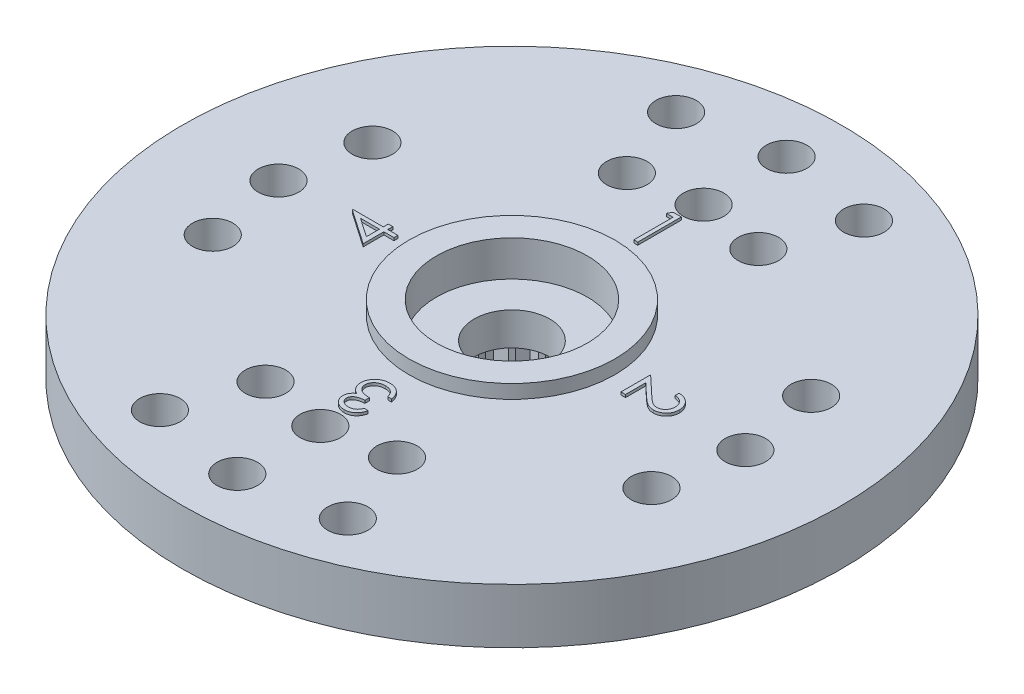
from build123d import *

# Parameters (mm, degrees)
SKETCH1_R           = 12
SKETCH1_R_2         = 1.375
SKETCH1_R_3         = 0.7366
BOSS_EXTRUDE1_DEPTH = 2
SKETCH2_R           = 3.75
SKETCH2_R_2         = 2.75
BOSS_EXTRUDE2_DEPTH = 0.5
SKETCH3_R           = 2.75
SKETCH3_R_2         = 1.375
CUT_EXTRUDE1_DEPTH  = 0.8
SKETCH4_R           = 4.5
SKETCH4_R_2         = 2.5
BOSS_EXTRUDE3_DEPTH = 2.5
CUT_EXTRUDE3_DEPTH  = 2.5
BOSS_EXTRUDE4_DEPTH = 0.1


with BuildPart() as part:
    # Sketch1 → Boss-Extrude1 (new body)
    with BuildSketch(Plane(origin=(0, 0, 0), x_dir=(1, 0, 0), z_dir=(0, 1, 0))):
        with Locations(Location((0, 0, 0), (0, 0, 270))):
            Circle(SKETCH1_R)
        with Locations(Location((0, 0, 0), (0, 0, 270))):
            Circle(SKETCH1_R_2, mode=Mode.SUBTRACT)
        with Locations(Location((0, 10, 0), (0, 0, 270))):
            Circle(SKETCH1_R_3, mode=Mode.SUBTRACT)
        with Locations(Location((-3.420201433, 9.396926208, 0), (0, 0, 270))):
            Circle(SKETCH1_R_3, mode=Mode.SUBTRACT)
        with Locations(Location((3.420201433, 9.396926208, 0), (0, 0, 270))):
            Circle(SKETCH1_R_3, mode=Mode.SUBTRACT)
        with Locations(Location((0, 6.977694875, 0), (0, 0, 270))):
            Circle(SKETCH1_R_3, mode=Mode.SUBTRACT)
        with Locations(Location((-2.394141003, 6.577848346, 0), (0, 0, 270))):
            Circle(SKETCH1_R_3, mode=Mode.SUBTRACT)
        with Locations(Location((2.394141003, 6.577848346, 0), (0, 0, 270))):
            Circle(SKETCH1_R_3, mode=Mode.SUBTRACT)
        with Locations(Location((8.5, 0, 0), (0, 0, 270))):
            Circle(SKETCH1_R_3, mode=Mode.SUBTRACT)
        with Locations(Location((7.987387277, 2.907171218, 0), (0, 0, 270))):
            Circle(SKETCH1_R_3, mode=Mode.SUBTRACT)
        with Locations(Location((7.987387277, -2.907171218, 0), (0, 0, 270))):
            Circle(SKETCH1_R_3, mode=Mode.SUBTRACT)
        with Locations(Location((-2.394141003, -6.577848346, 0), (0, 0, 90))):
            Circle(SKETCH1_R_3, mode=Mode.SUBTRACT)
        with Locations(Location((0, -6.977694875, 0), (0, 0, 90))):
            Circle(SKETCH1_R_3, mode=Mode.SUBTRACT)
        with Locations(Location((2.394141003, -6.577848346, 0), (0, 0, 90))):
            Circle(SKETCH1_R_3, mode=Mode.SUBTRACT)
        with Locations(Location((3.420201433, -9.396926208, 0), (0, 0, 90))):
            Circle(SKETCH1_R_3, mode=Mode.SUBTRACT)
        with Locations(Location((0, -10, 0), (0, 0, 90))):
            Circle(SKETCH1_R_3, mode=Mode.SUBTRACT)
        with Locations(Location((-3.420201433, -9.396926208, 0), (0, 0, 90))):
            Circle(SKETCH1_R_3, mode=Mode.SUBTRACT)
        with Locations(Location((-7.987387277, -2.907171218, 0), (0, 0, 90))):
            Circle(SKETCH1_R_3, mode=Mode.SUBTRACT)
        with Locations(Location((-8.5, 0, 0), (0, 0, 90))):
            Circle(SKETCH1_R_3, mode=Mode.SUBTRACT)
        with Locations(Location((-7.987387277, 2.907171218, 0), (0, 0, 90))):
            Circle(SKETCH1_R_3, mode=Mode.SUBTRACT)
    extrude(amount=BOSS_EXTRUDE1_DEPTH)

    # Sketch2 → Boss-Extrude2 (add)
    with BuildSketch(Plane(origin=(0, 2, 0), x_dir=(1, 0, 0), z_dir=(0, 1, 0))):
        with Locations(Location((0, 0, 0), (0, 0, 270))):
            Circle(SKETCH2_R)
        with Locations(Location((0, 0, 0), (0, 0, 270))):
            Circle(SKETCH2_R_2, mode=Mode.SUBTRACT)
    extrude(amount=BOSS_EXTRUDE2_DEPTH)

    # Sketch3 → Cut-Extrude1 (cut)
    with BuildSketch(Plane(origin=(0, 2, 0), x_dir=(1, 0, 0), z_dir=(0, 1, 0))):
        with Locations(Location((0, 0, 0), (0, 0, 270))):
            Circle(SKETCH3_R)
        with Locations(Location((0, 0, 0), (0, 0, 270))):
            Circle(SKETCH3_R_2, mode=Mode.SUBTRACT)
    extrude(amount=-CUT_EXTRUDE1_DEPTH, mode=Mode.SUBTRACT)

    # Sketch4 → Boss-Extrude3 (add)
    with BuildSketch(Plane.XZ):
        with Locations(Location((0, 0, 0), (0, 0, 90))):
            Circle(SKETCH4_R)
        with Locations(Location((0, 0, 0), (0, 0, 270))):
            Circle(SKETCH4_R_2, mode=Mode.SUBTRACT)
    extrude(amount=BOSS_EXTRUDE3_DEPTH)

    # Sketch5 → Cut-Extrude3 (cut)
    with BuildSketch(Plane.XZ.offset(2.5)):
        with BuildLine():
            Line((0.299038106, 2.482050808), (0, 3))
            Line((0, 3), (-0.299038106, 2.482050808))
            ThreePointArc((-0.299038106, 2.482050808), (-0.391086163, 2.469220851), (-0.482593741, 2.452978451))
            Line((-0.482593741, 2.452978451), (-0.927050983, 2.853169549))
            Line((-0.927050983, 2.853169549), (-1.051398019, 2.268162738))
            ThreePointArc((-1.051398019, 2.268162738), (-1.134976249, 2.22751631), (-1.216985951, 2.183791473))
            Line((-1.216985951, 2.183791473), (-1.763355757, 2.427050983))
            Line((-1.763355757, 2.427050983), (-1.70083977, 1.832251096))
            ThreePointArc((-1.70083977, 1.832251096), (-1.767766953, 1.767766953), (-1.832251096, 1.70083977))
            Line((-1.832251096, 1.70083977), (-2.427050983, 1.763355757))
            Line((-2.427050983, 1.763355757), (-2.183791473, 1.216985951))
            ThreePointArc((-2.183791473, 1.216985951), (-2.22751631, 1.134976249), (-2.268162738, 1.051398019))
            Line((-2.268162738, 1.051398019), (-2.853169549, 0.927050983))
            Line((-2.853169549, 0.927050983), (-2.452978451, 0.482593741))
            ThreePointArc((-2.452978451, 0.482593741), (-2.469220851, 0.391086163), (-2.482050808, 0.299038106))
            Line((-2.482050808, 0.299038106), (-3, 0))
            Line((-3, 0), (-2.482050808, -0.299038106))
            ThreePointArc((-2.482050808, -0.299038106), (-2.469220851, -0.391086163), (-2.452978451, -0.482593741))
            Line((-2.452978451, -0.482593741), (-2.853169549, -0.927050983))
            Line((-2.853169549, -0.927050983), (-2.268162738, -1.051398019))
            ThreePointArc((-2.268162738, -1.051398019), (-2.22751631, -1.134976249), (-2.183791473, -1.216985951))
            Line((-2.183791473, -1.216985951), (-2.427050983, -1.763355757))
            Line((-2.427050983, -1.763355757), (-1.832251096, -1.70083977))
            ThreePointArc((-1.832251096, -1.70083977), (-1.767766953, -1.767766953), (-1.70083977, -1.832251096))
            Line((-1.70083977, -1.832251096), (-1.763355757, -2.427050983))
            Line((-1.763355757, -2.427050983), (-1.216985951, -2.183791473))
            ThreePointArc((-1.216985951, -2.183791473), (-1.134976249, -2.22751631), (-1.051398019, -2.268162738))
            Line((-1.051398019, -2.268162738), (-0.927050983, -2.853169549))
            Line((-0.927050983, -2.853169549), (-0.482593741, -2.452978451))
            ThreePointArc((-0.482593741, -2.452978451), (-0.391086163, -2.469220851), (-0.299038106, -2.482050808))
            Line((-0.299038106, -2.482050808), (0, -3))
            Line((0, -3), (0.299038106, -2.482050808))
            ThreePointArc((0.299038106, -2.482050808), (0.391086163, -2.469220851), (0.482593741, -2.452978451))
            Line((0.482593741, -2.452978451), (0.927050983, -2.853169549))
            Line((0.927050983, -2.853169549), (1.051398019, -2.268162738))
            ThreePointArc((1.051398019, -2.268162738), (1.134976249, -2.22751631), (1.216985951, -2.183791473))
            Line((1.216985951, -2.183791473), (1.763355757, -2.427050983))
            Line((1.763355757, -2.427050983), (1.70083977, -1.832251096))
            ThreePointArc((1.70083977, -1.832251096), (1.767766953, -1.767766953), (1.832251096, -1.70083977))
            Line((1.832251096, -1.70083977), (2.427050983, -1.763355757))
            Line((2.427050983, -1.763355757), (2.183791473, -1.216985951))
            ThreePointArc((2.183791473, -1.216985951), (2.22751631, -1.134976249), (2.268162738, -1.051398019))
            Line((2.268162738, -1.051398019), (2.853169549, -0.927050983))
            Line((2.853169549, -0.927050983), (2.452978451, -0.482593741))
            ThreePointArc((2.452978451, -0.482593741), (2.469220851, -0.391086163), (2.482050808, -0.299038106))
            Line((2.482050808, -0.299038106), (3, 0))
            Line((3, 0), (2.482050808, 0.299038106))
            ThreePointArc((2.482050808, 0.299038106), (2.469220851, 0.391086163), (2.452978451, 0.482593741))
            Line((2.452978451, 0.482593741), (2.853169549, 0.927050983))
            Line((2.853169549, 0.927050983), (2.268162738, 1.051398019))
            ThreePointArc((2.268162738, 1.051398019), (2.22751631, 1.134976249), (2.183791473, 1.216985951))
            Line((2.183791473, 1.216985951), (2.427050983, 1.763355757))
            Line((2.427050983, 1.763355757), (1.832251096, 1.70083977))
            ThreePointArc((1.832251096, 1.70083977), (1.767766953, 1.767766953), (1.70083977, 1.832251096))
            Line((1.70083977, 1.832251096), (1.763355757, 2.427050983))
            Line((1.763355757, 2.427050983), (1.216985951, 2.183791473))
            ThreePointArc((1.216985951, 2.183791473), (1.134976249, 2.22751631), (1.051398019, 2.268162738))
            Line((1.051398019, 2.268162738), (0.927050983, 2.853169549))
            Line((0.927050983, 2.853169549), (0.482593741, 2.452978451))
            ThreePointArc((0.482593741, 2.452978451), (0.391086163, 2.469220851), (0.299038106, 2.482050808))
        make_face()
    extrude(amount=-CUT_EXTRUDE3_DEPTH, mode=Mode.SUBTRACT)

    # Sketch6 → Boss-Extrude4 (add)
    with BuildSketch(Plane(origin=(0, 2, 0), x_dir=(1, 0, 0), z_dir=(0, 1, 0))):
        Polygon((-0.212111879, 6.0875), (0.081410256, 6.0875), (0.081410256, 4.5), (-0.061057692, 4.5), (-0.061057692, 5.924679487), (-0.305288462, 5.924679487), align=None)
        with BuildLine():
            Line((5.599038462, 0.34599359), (5.599038462, 0.488461538))
            add(Edge.make_bspline(
                [(5.599038462, 0.488461538), (5.617939279, 0.487533166), (5.655059981, 0.485709868), (5.709180577, 0.477167658), (5.760917347, 0.46495614), (5.809826741, 0.447649569), (5.856493025, 0.426277468), (5.900296523, 0.40011183), (5.941671981, 0.369710466), (5.979836023, 0.335129148), (6.014722729, 0.29760523), (6.045167992, 0.25736354), (6.070596953, 0.214817686), (6.091970581, 0.170336692), (6.107994605, 0.123406123), (6.119889389, 0.074474582), (6.127044708, 0.023320904), (6.12781392, -0.011531495), (6.128205128, -0.029256811)],
                knots=[0, 0, 0, 0, 1.100776268, 2.161895295, 3.184016182, 4.190939212, 5.176500551, 6.166955529, 7.155448256, 8.160289653, 9.16017456, 10.133824356, 11.091467644, 12.04088621, 13.000931625, 13.972173743, 14.968683325, 16, 16, 16, 16], degree=3))
            add(Edge.make_bspline(
                [(6.128205128, -0.029256811), (6.127797614, -0.046664009), (6.126996863, -0.080868531), (6.120120254, -0.130789516), (6.109349932, -0.178313503), (6.094239011, -0.223347597), (6.073926074, -0.265532491), (6.049525047, -0.305185086), (6.02130391, -0.342777454), (5.988078073, -0.376616959), (5.952607706, -0.407690267), (5.914739978, -0.434497361), (5.875628838, -0.457454046), (5.834976046, -0.476589172), (5.79239883, -0.490675349), (5.748517063, -0.501369751), (5.702876523, -0.507414685), (5.671985336, -0.50834243), (5.656280048, -0.508814103)],
                knots=[0, 0, 0, 0, 1.111607364, 2.184268762, 3.212621178, 4.221274766, 5.211760367, 6.196651075, 7.1921475, 8.207485113, 9.220403448, 10.201281604, 11.166441695, 12.114753415, 13.065576456, 14.026450734, 14.996634279, 16, 16, 16, 16], degree=3))
            add(Edge.make_bspline(
                [(5.656280048, -0.508814103), (5.634169423, -0.508046087), (5.590336183, -0.506523533), (5.525922299, -0.493499512), (5.463513856, -0.473158416), (5.413286579, -0.448666758), (5.372812816, -0.423959614), (5.339489511, -0.401694923), (5.30360953, -0.375630526), (5.265293024, -0.345387065), (5.224239863, -0.311590155), (5.180474849, -0.273933674), (5.134450153, -0.232149094), (5.103015113, -0.202821846), (5.086726262, -0.1876252)],
                knots=[0, 0, 0, 0, 1.184426356, 2.348067706, 3.509069118, 4.696110526, 5.333549288, 6.050745305, 6.844228056, 7.710549037, 8.667450064, 9.695053472, 10.805634456, 12, 12, 12, 12], degree=3))
            Line((5.086726262, -0.1876252), (4.662820513, 0.209567808))
            Line((4.662820513, 0.209567808), (4.662820513, -0.529166667))
            Line((4.662820513, -0.529166667), (4.5, -0.529166667))
            Line((4.5, -0.529166667), (4.5, 0.549519231))
            Line((4.5, 0.549519231), (5.15700621, -0.066145833))
            add(Edge.make_bspline(
                [(5.15700621, -0.066145833), (5.172652803, -0.081136472), (5.202706705, -0.10993042), (5.246597776, -0.15063927), (5.287268318, -0.187261175), (5.324898551, -0.219820431), (5.359275147, -0.248343825), (5.390667508, -0.272740096), (5.418806234, -0.293117072), (5.451862432, -0.31471242), (5.492269991, -0.335305017), (5.541401752, -0.353403803), (5.592090897, -0.364360562), (5.626334746, -0.36568164), (5.643559696, -0.366346154)],
                knots=[0, 0, 0, 0, 1.329530082, 2.553755191, 3.672934919, 4.687409497, 5.60679272, 6.413407421, 7.126401618, 7.737995624, 8.834647426, 9.90044882, 10.943907757, 12, 12, 12, 12], degree=3))
            add(Edge.make_bspline(
                [(5.643559696, -0.366346154), (5.654392812, -0.366060761), (5.675742806, -0.365498307), (5.707024672, -0.360440353), (5.737316681, -0.353009214), (5.766244292, -0.341555532), (5.794376458, -0.327794356), (5.820857871, -0.310213439), (5.846591221, -0.290123068), (5.87069413, -0.266819222), (5.892776139, -0.241235929), (5.912335573, -0.214204803), (5.928681993, -0.185607306), (5.94208205, -0.155562618), (5.952593749, -0.124154868), (5.959877459, -0.091323211), (5.964450586, -0.057158391), (5.965069336, -0.033829626), (5.965384615, -0.021942608)],
                knots=[0, 0, 0, 0, 0.991504627, 1.954065223, 2.895985987, 3.842598665, 4.797835564, 5.759220273, 6.74786863, 7.784730864, 8.824135544, 9.839918996, 10.835834653, 11.835434876, 12.84861661, 13.863796685, 14.911511676, 16, 16, 16, 16], degree=3))
            add(Edge.make_bspline(
                [(5.965384615, -0.021942608), (5.965060395, -0.009527925), (5.964423681, 0.014852462), (5.959967009, 0.050647099), (5.952285925, 0.084797422), (5.941755322, 0.117372561), (5.928497209, 0.148403903), (5.911665037, 0.177610862), (5.891915995, 0.205260088), (5.869403165, 0.231300798), (5.844219896, 0.255228126), (5.816492727, 0.276692883), (5.786041295, 0.295000051), (5.753553406, 0.311228532), (5.718165248, 0.323645722), (5.680734357, 0.334259816), (5.64072893, 0.341970171), (5.613166096, 0.344630175), (5.599038462, 0.34599359)],
                knots=[0, 0, 0, 0, 1.031212865, 2.025131798, 2.990757446, 3.934781266, 4.865570067, 5.788494791, 6.729227313, 7.684356718, 8.643577152, 9.610526866, 10.590658432, 11.59095419, 12.621640561, 13.700587263, 14.82141059, 16, 16, 16, 16], degree=3))
        make_face()
        with BuildLine():
            Line((0.34599359, -5.721153846), (0.488461538, -5.721153846))
            add(Edge.make_bspline(
                [(0.488461538, -5.721153846), (0.484601849, -5.737134294), (0.477056473, -5.768374763), (0.461318645, -5.813009485), (0.444173983, -5.855247654), (0.423586782, -5.894298373), (0.401131025, -5.930946447), (0.37540322, -5.964360657), (0.347590345, -5.995390823), (0.316826886, -6.022928613), (0.284564958, -6.04786494), (0.250349969, -6.069126127), (0.2148703, -6.08741601), (0.177880129, -6.102483759), (0.139269329, -6.113834621), (0.099386965, -6.122070029), (0.05812852, -6.127418142), (0.030121577, -6.127940095), (0.015900441, -6.128205128)],
                knots=[0, 0, 0, 0, 1.162005537, 2.271625781, 3.343758855, 4.383309926, 5.390229558, 6.379919256, 7.361854164, 8.333198761, 9.295911338, 10.242430842, 11.177959212, 12.116337295, 13.062827104, 14.020064771, 14.994644689, 16, 16, 16, 16], degree=3))
            add(Edge.make_bspline(
                [(0.015900441, -6.128205128), (-0.004819946, -6.127579549), (-0.045808747, -6.126342036), (-0.106026272, -6.115041559), (-0.164095579, -6.097159445), (-0.21938106, -6.072451719), (-0.270733706, -6.041977474), (-0.316424762, -6.005707754), (-0.355834908, -5.964342356), (-0.388897715, -5.918652943), (-0.414785304, -5.86982348), (-0.43387448, -5.819567694), (-0.445495743, -5.7680048), (-0.447001853, -5.733189891), (-0.44775641, -5.715747696)],
                knots=[0, 0, 0, 0, 1.083050992, 2.142477498, 3.193116406, 4.255571735, 5.30263384, 6.308962982, 7.297363603, 8.282367274, 9.249857812, 10.179914175, 11.08814088, 12, 12, 12, 12], degree=3))
            add(Edge.make_bspline(
                [(-0.44775641, -5.715747696), (-0.447228639, -5.698962472), (-0.446195871, -5.666116392), (-0.437426655, -5.618164141), (-0.422669136, -5.572969558), (-0.402226779, -5.530342388), (-0.375764719, -5.490552907), (-0.343709603, -5.453511592), (-0.305835181, -5.419054153), (-0.277133663, -5.399314963), (-0.262357272, -5.389152644)],
                knots=[0, 0, 0, 0, 1.024540389, 2.004866551, 2.965041327, 3.920577974, 4.882998113, 5.874504559, 6.905732034, 8, 8, 8, 8], degree=3))
            add(Edge.make_bspline(
                [(-0.262357272, -5.389152644), (-0.279266057, -5.38102782), (-0.312821544, -5.364904106), (-0.358097689, -5.332780608), (-0.399825574, -5.296601576), (-0.422822908, -5.268052723), (-0.43440004, -5.253680889)],
                knots=[0, 0, 0, 0, 1.015663554, 2.015584519, 3.001021554, 4, 4, 4, 4], degree=3))
            add(Edge.make_bspline(
                [(-0.43440004, -5.253680889), (-0.442041901, -5.243223667), (-0.457200483, -5.222480465), (-0.475858316, -5.189110161), (-0.492978135, -5.155480456), (-0.505577827, -5.120269074), (-0.516450862, -5.084607067), (-0.523604956, -5.047730768), (-0.528197599, -5.009990535), (-0.5288425, -4.984446887), (-0.529166667, -4.971607071)],
                knots=[0, 0, 0, 0, 1.02516404, 2.033540309, 3.025129118, 4.011046665, 4.991655828, 5.976607087, 6.982917762, 8, 8, 8, 8], degree=3))
            add(Edge.make_bspline(
                [(-0.529166667, -4.971607071), (-0.528350817, -4.94937866), (-0.526722958, -4.905026444), (-0.512235463, -4.839481871), (-0.489636803, -4.775530087), (-0.458141824, -4.71407805), (-0.418998333, -4.656756936), (-0.372686258, -4.605322495), (-0.319156288, -4.561514187), (-0.259966982, -4.524586511), (-0.195593193, -4.495321744), (-0.127013944, -4.474234108), (-0.05463527, -4.461584484), (-0.005138768, -4.460066765), (0.020034555, -4.459294872)],
                knots=[0, 0, 0, 0, 0.955619592, 1.906742024, 2.874954321, 3.868585453, 4.869520953, 5.854611167, 6.836527075, 7.836578462, 8.849204403, 9.870874567, 10.917152508, 12, 12, 12, 12], degree=3))
            add(Edge.make_bspline(
                [(0.020034555, -4.459294872), (0.037005812, -4.459692103), (0.070399587, -4.460473722), (0.11951096, -4.465721886), (0.166290723, -4.475567824), (0.211193125, -4.487950453), (0.253540479, -4.505070826), (0.293941914, -4.525481482), (0.332220335, -4.549705826), (0.36814842, -4.577784596), (0.401687783, -4.60921458), (0.431983954, -4.644517919), (0.459372127, -4.683035728), (0.48367828, -4.725114484), (0.50500471, -4.770636328), (0.52289247, -4.819783675), (0.538510693, -4.872175513), (0.545786309, -4.908676289), (0.549519231, -4.927403846)],
                knots=[0, 0, 0, 0, 1.048603596, 2.063302207, 3.045874044, 3.999447474, 4.937100059, 5.862643889, 6.7929026, 7.7308982, 8.676022965, 9.627908155, 10.600123445, 11.591992905, 12.626222643, 13.701663232, 14.820785756, 16, 16, 16, 16], degree=3))
            Line((0.549519231, -4.927403846), (0.407051282, -4.927403846))
            add(Edge.make_bspline(
                [(0.407051282, -4.927403846), (0.403339575, -4.915180544), (0.396119982, -4.891405159), (0.383830783, -4.857187592), (0.369829816, -4.825819475), (0.354809999, -4.797070701), (0.339035489, -4.770658147), (0.321384791, -4.747280228), (0.303165214, -4.725910119), (0.289431365, -4.713870241), (0.282709836, -4.707977764)],
                knots=[0, 0, 0, 0, 1.198163088, 2.33053128, 3.407730985, 4.417276592, 5.372219308, 6.28897303, 7.162600585, 8, 8, 8, 8], degree=3))
            add(Edge.make_bspline(
                [(0.282709836, -4.707977764), (0.273820396, -4.701127882), (0.256068955, -4.68744926), (0.227160407, -4.669943613), (0.196651098, -4.654959198), (0.164286602, -4.642779237), (0.130062577, -4.63363652), (0.094117851, -4.627056022), (0.056393446, -4.622711871), (0.030647277, -4.622317113), (0.017490485, -4.622115385)],
                knots=[0, 0, 0, 0, 0.946083416, 1.889246487, 2.84504177, 3.809995578, 4.801312957, 5.829064617, 6.89060985, 8, 8, 8, 8], degree=3))
            add(Edge.make_bspline(
                [(0.017490485, -4.622115385), (0.002634231, -4.622394287), (-0.026415892, -4.622939657), (-0.068801536, -4.627969629), (-0.109137453, -4.635263244), (-0.147012014, -4.646671877), (-0.182940598, -4.660358417), (-0.216121178, -4.678276609), (-0.247529219, -4.69851231), (-0.276244612, -4.722050322), (-0.302132943, -4.747492366), (-0.324503322, -4.774484107), (-0.343878628, -4.802188626), (-0.35945314, -4.831252213), (-0.371773311, -4.861389777), (-0.380155306, -4.892714125), (-0.385984774, -4.924961484), (-0.386459435, -4.946882168), (-0.386698718, -4.957932692)],
                knots=[0, 0, 0, 0, 1.216990249, 2.379719373, 3.493992396, 4.571561497, 5.616923107, 6.638958652, 7.655775068, 8.674704564, 9.676001865, 10.625896028, 11.54399481, 12.441854662, 13.322657739, 14.20572845, 15.095482574, 16, 16, 16, 16], degree=3))
            add(Edge.make_bspline(
                [(-0.386698718, -4.957932692), (-0.386003169, -4.972723335), (-0.384615531, -5.002231023), (-0.374065118, -5.0456597), (-0.356555994, -5.087519235), (-0.332520572, -5.127261442), (-0.302560837, -5.163663871), (-0.268092983, -5.196247969), (-0.228381575, -5.223379244), (-0.191624295, -5.242072337), (-0.158981256, -5.254526807), (-0.131102444, -5.263260269), (-0.099863368, -5.270241472), (-0.06563939, -5.276994458), (-0.028286064, -5.282655717), (0.012230232, -5.287397248), (0.055925805, -5.291185256), (0.086174952, -5.292877803), (0.101762821, -5.29375)],
                knots=[0, 0, 0, 0, 1.070440979, 2.135555593, 3.216243406, 4.345886539, 5.486149072, 6.621334998, 7.769144672, 8.957074012, 9.598644492, 10.297969361, 11.070758978, 11.915404831, 12.824182859, 13.805940418, 14.869366021, 16, 16, 16, 16], degree=3))
            Line((0.101762821, -5.29375), (0.101762821, -5.456570513))
            add(Edge.make_bspline(
                [(0.101762821, -5.456570513), (0.082130288, -5.456953283), (0.043688426, -5.457702772), (-0.012623157, -5.464900992), (-0.066305692, -5.47658472), (-0.116551716, -5.492896722), (-0.162112282, -5.512755295), (-0.202016873, -5.53498931), (-0.234829912, -5.560639777), (-0.261139083, -5.588494162), (-0.280652882, -5.618558339), (-0.295056815, -5.64975068), (-0.303576438, -5.682651469), (-0.304715777, -5.70510004), (-0.305288462, -5.716383714)],
                knots=[0, 0, 0, 0, 1.321816535, 2.58820849, 3.816448615, 5.017641336, 6.139869627, 7.160068286, 8.085608132, 8.934319198, 9.728416342, 10.48890201, 11.240453369, 12, 12, 12, 12], degree=3))
            add(Edge.make_bspline(
                [(-0.305288462, -5.716383714), (-0.305104632, -5.724675376), (-0.304738912, -5.741171245), (-0.299942506, -5.765346601), (-0.293068021, -5.788783239), (-0.283080788, -5.811207319), (-0.270164259, -5.832690124), (-0.254537181, -5.853310117), (-0.236159971, -5.8732642), (-0.215151965, -5.892112288), (-0.191706493, -5.9090759), (-0.166764563, -5.924198724), (-0.140228938, -5.936914866), (-0.112272542, -5.947455684), (-0.082744259, -5.95537096), (-0.051799429, -5.961057912), (-0.019374439, -5.964612556), (0.002746995, -5.965124413), (0.013992388, -5.965384615)],
                knots=[0, 0, 0, 0, 0.884246871, 1.759167212, 2.622361933, 3.489113179, 4.372562419, 5.294145153, 6.247651513, 7.265905295, 8.30305477, 9.334068495, 10.37719476, 11.441246459, 12.52060732, 13.637552802, 14.799054011, 16, 16, 16, 16], degree=3))
            add(Edge.make_bspline(
                [(0.013992388, -5.965384615), (0.032068563, -5.964754757), (0.067375538, -5.963524498), (0.118264696, -5.952711076), (0.16552422, -5.935578323), (0.201526445, -5.914890575), (0.228156868, -5.894539373), (0.24755157, -5.877031234), (0.266250048, -5.85718059), (0.283518559, -5.83444296), (0.300391868, -5.809600201), (0.31670886, -5.782515486), (0.331945433, -5.752802669), (0.341220184, -5.73190776), (0.34599359, -5.721153846)],
                knots=[0, 0, 0, 0, 1.4727372, 2.876598283, 4.222346151, 5.558423782, 6.24313385, 6.953189256, 7.68715613, 8.463578749, 9.278833271, 10.135787152, 11.040551781, 12, 12, 12, 12], degree=3))
        make_face()
        Polygon((-6.128205128, 0.317054788), (-6.128205128, 0.34599359), (-5.029166667, 0.34599359), (-5.029166667, 0.529166667), (-4.866346154, 0.529166667), (-4.866346154, 0.34599359), (-4.5, 0.34599359), (-4.5, 0.203525641), (-4.866346154, 0.203525641), (-4.866346154, -0.549519231), align=None)
        Polygon((-5.029166667, 0.203525641), (-5.718609776, 0.203525641), (-5.029166667, -0.269671474), align=None, mode=Mode.SUBTRACT)
    extrude(amount=BOSS_EXTRUDE4_DEPTH)


solid = part.part
